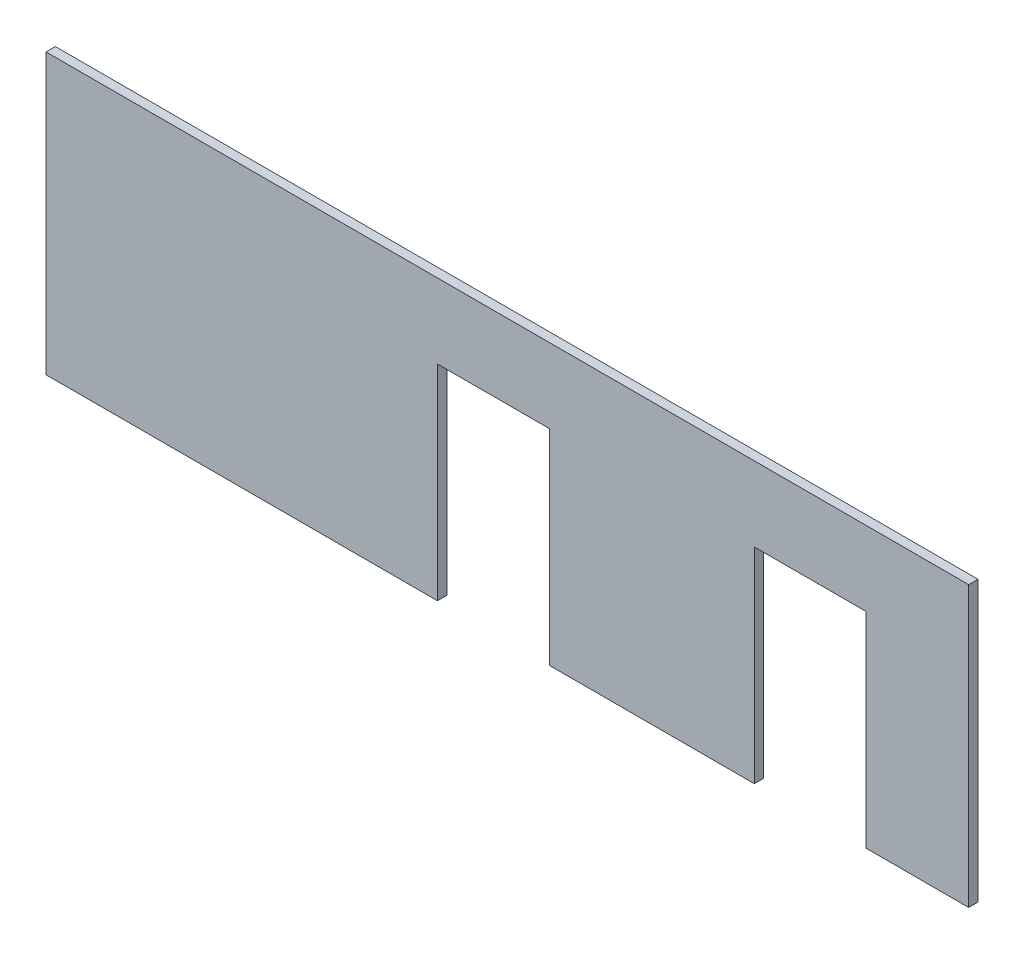
from build123d import *

# Parameters (mm, degrees)
BOSS_EXTRUDE1_DEPTH = 5


with BuildPart() as part:
    # Sketch1 → Boss-Extrude1 (new body)
    with BuildSketch(Plane.XY):
        Polygon((-247.5, 75), (247.5, 75), (247.5, -75), (192.5, -75), (192.5, 35), (132.5, 35), (132.5, -75), (22.5, -75), (22.5, 35), (-37.5, 35), (-37.5, -75), (-247.5, -75), align=None)
    extrude(amount=BOSS_EXTRUDE1_DEPTH)


solid = part.part
